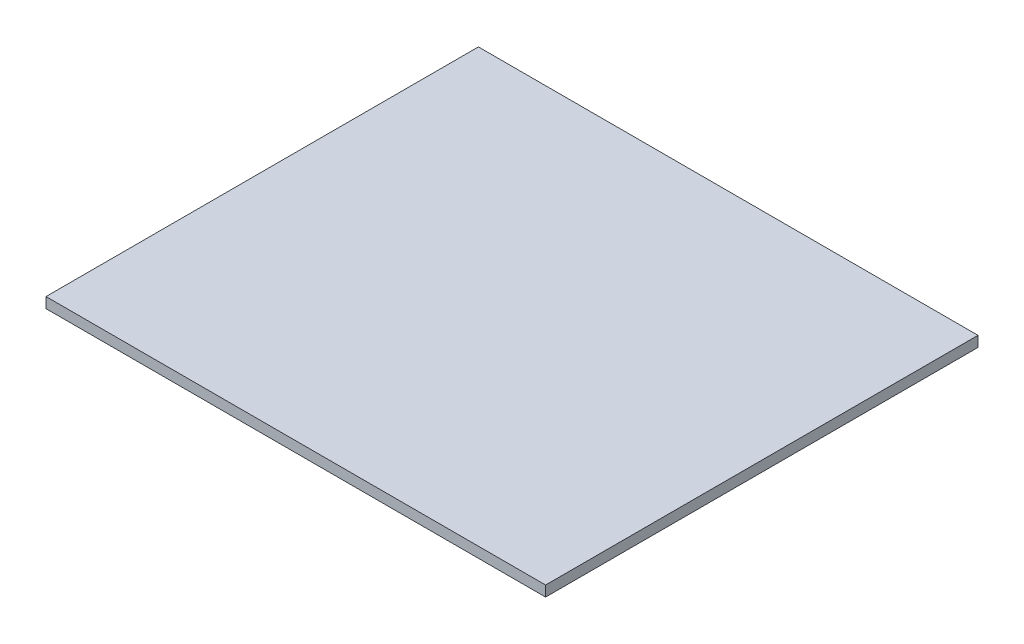
from build123d import *

# Parameters (mm, degrees)
SKETCH1_W           = 119
SKETCH1_H           = 103
BOSS_EXTRUDE1_DEPTH = 2.5


with BuildPart() as part:
    # Sketch1 → Boss-Extrude1 (new body)
    with BuildSketch(Plane(origin=(0, 0, 0), x_dir=(1, 0, 0), z_dir=(0, 1, 0))):
        Rectangle(SKETCH1_W, SKETCH1_H)
    extrude(amount=BOSS_EXTRUDE1_DEPTH)


solid = part.part
